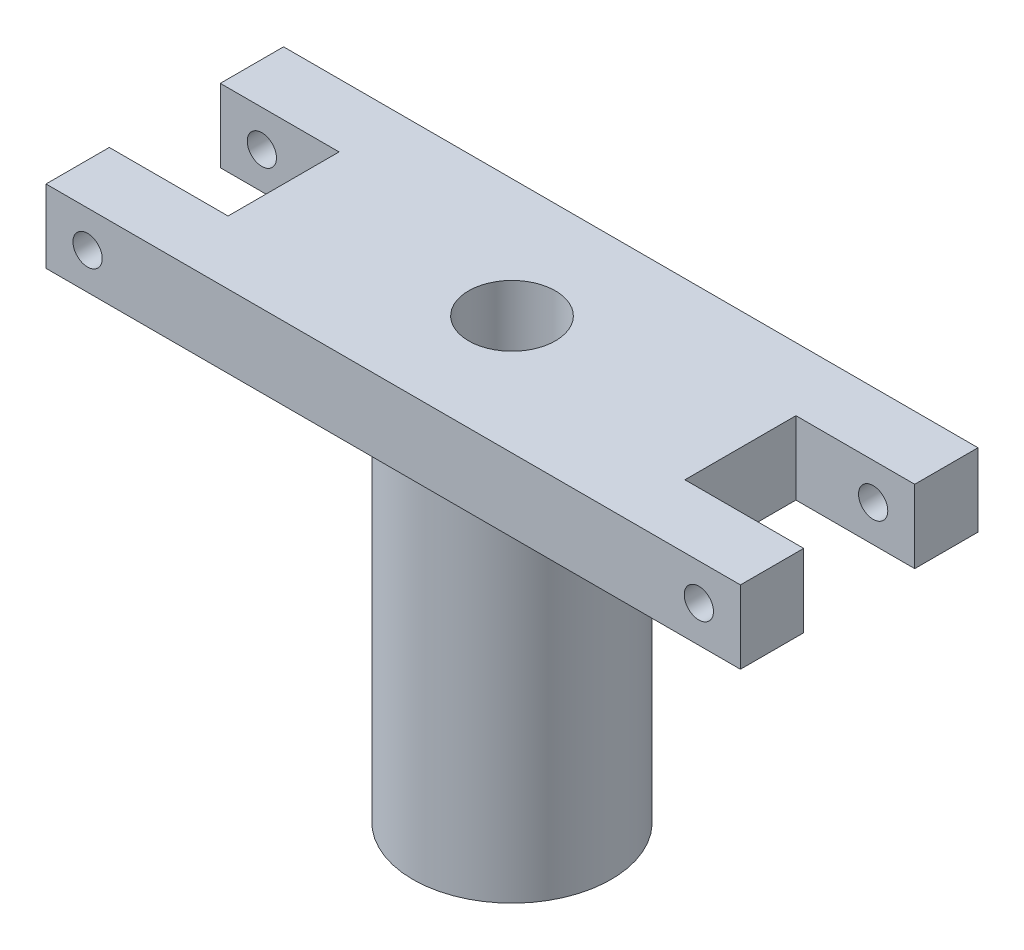
from build123d import *

# Parameters (mm, degrees)
SKETCH_10_R         = 10.85
EXTRUDE_5_DEPTH     = 40
CUT_EXTRUDE_1_DEPTH = 18
SKETCH_12_R         = 4.75
CUT_EXTRUDE_2_DEPTH = 18
SKETCH_13_R         = 2.1
CUT_EXTRUDE_3_DEPTH = 4
SKETCH_14_W         = 76
SKETCH_14_H         = 26
EXTRUDE_8_DEPTH     = 8
SKETCH_15_R         = 4.75
CUT_EXTRUDE_4_DEPTH = 8
SKETCH_16_R         = 1.6
CUT_EXTRUDE_5_DEPTH = 26
SKETCH_17_W         = 13
SKETCH_17_H         = 12.15
CUT_EXTRUDE_6_DEPTH = 8


with BuildPart() as part:
    # 草图10 → 凸台-拉伸5 (new body)
    with BuildSketch(Plane(origin=(0, 0, 0), x_dir=(1, 0, 0), z_dir=(0, 1, 0))):
        Circle(SKETCH_10_R)
    extrude(amount=EXTRUDE_5_DEPTH)

    # 草图11 → 切除-拉伸1 (cut)
    with BuildSketch(Plane(origin=(0, 0, 0), x_dir=(-1, 0, 0), z_dir=(0, -1, 0))):
        Polygon((5.739953665, -4.542612896), (6.803995, 2.699639243), (1.064041335, 7.242252139), (-5.739953665, 4.542612896), (-6.803995, -2.699639243), (-1.064041335, -7.242252139), align=None)
    extrude(amount=-CUT_EXTRUDE_1_DEPTH, mode=Mode.SUBTRACT)

    # 草图12 → 切除-拉伸2 (cut)
    with BuildSketch(Plane(origin=(0, 40, 0), x_dir=(1, 0, 0), z_dir=(0, 1, 0))):
        Circle(SKETCH_12_R)
    extrude(amount=-CUT_EXTRUDE_2_DEPTH, mode=Mode.SUBTRACT)

    # 草图13 → 切除-拉伸3 (cut)
    with BuildSketch(Plane(origin=(0, 22, 0), x_dir=(1, 0, 0), z_dir=(0, 1, 0))):
        Circle(SKETCH_13_R)
    extrude(amount=-CUT_EXTRUDE_3_DEPTH, mode=Mode.SUBTRACT)

    # 草图14 → 凸台-拉伸8 (add)
    with BuildSketch(Plane(origin=(0, 40, 0), x_dir=(1, 0, 0), z_dir=(0, 1, 0))):
        Rectangle(SKETCH_14_W, SKETCH_14_H)
    extrude(amount=EXTRUDE_8_DEPTH)

    # 草图15 → 切除-拉伸4 (cut)
    with BuildSketch(Plane(origin=(0, 48, 0), x_dir=(1, 0, 0), z_dir=(0, 1, 0))):
        Circle(SKETCH_15_R)
    extrude(amount=-CUT_EXTRUDE_4_DEPTH, mode=Mode.SUBTRACT)

    # 草图16 → 切除-拉伸5 (cut)
    with BuildSketch(Plane.XY.offset(13)):
        with Locations((-33.45, 44)):
            Circle(SKETCH_16_R)
        with Locations((33.45, 44)):
            Circle(SKETCH_16_R)
    extrude(amount=-CUT_EXTRUDE_5_DEPTH, mode=Mode.SUBTRACT)

    # 草图17 → 切除-拉伸6 (cut)
    with BuildSketch(Plane.XZ.offset(-40)):
        with Locations((31.5, 0)):
            Rectangle(SKETCH_17_W, SKETCH_17_H)
        with Locations((-31.5, 0)):
            Rectangle(SKETCH_17_W, SKETCH_17_H)
    extrude(amount=-CUT_EXTRUDE_6_DEPTH, mode=Mode.SUBTRACT)


solid = part.part
